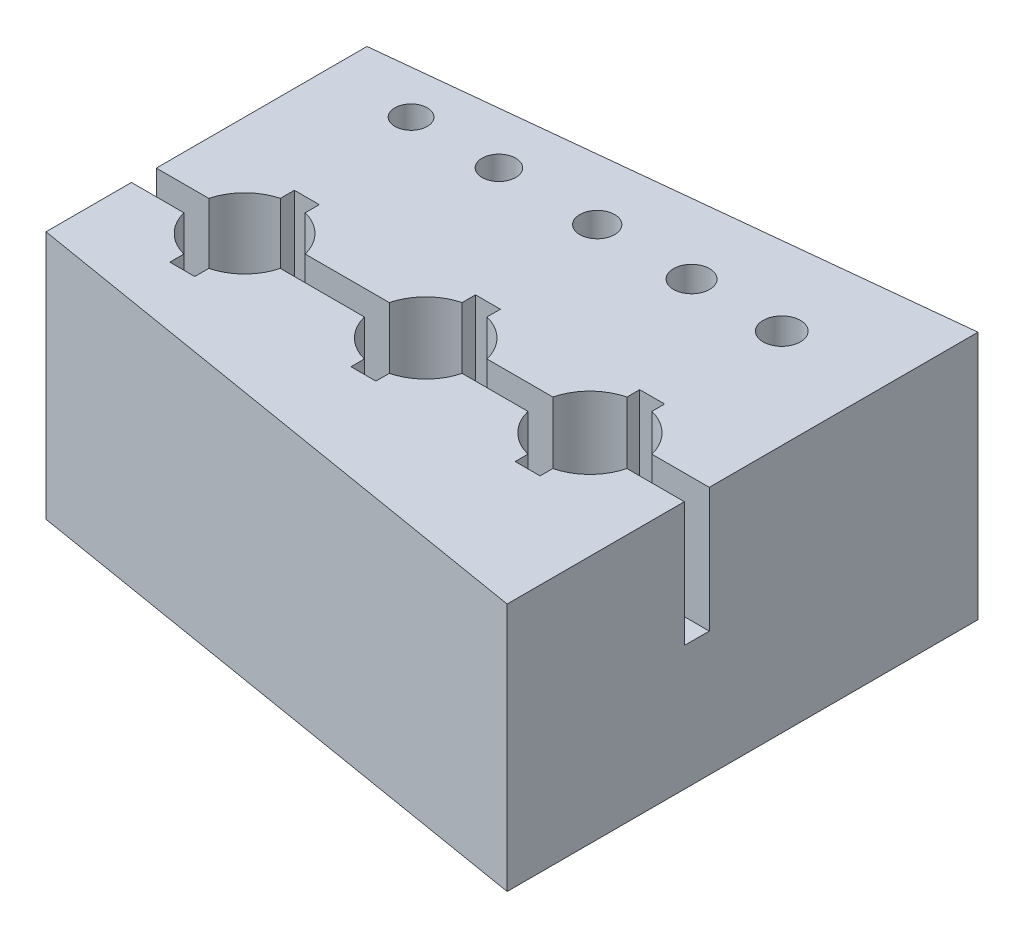
from build123d import *

# Parameters (mm, degrees)
SKETCH1_R           = 0.65
SKETCH1_R_2         = 0.675
SKETCH1_R_3         = 0.7
SKETCH1_R_4         = 0.725
SKETCH1_R_5         = 0.75
SKETCH1_W           = 1
SKETCH1_H           = 1
BOSS_EXTRUDE1_DEPTH = 10
CUT_EXTRUDE1_START  = 10
SKETCH1_4_W         = 1
SKETCH1_4_H         = 1
CUT_EXTRUDE1_DEPTH  = 5


with BuildPart() as part:
    # Sketch1 → Boss-Extrude1 (new body)
    with BuildSketch(Plane(origin=(0, 0, 0), x_dir=(1, 0, 0), z_dir=(0, 1, 0))):
        with BuildLine():
            Line((22.206609956, -4.676577902), (22.206609956, -1.693083106))
            Line((22.206609956, -1.693083106), (22.206609956, 6.115263516))
            Line((22.206609956, 6.115263516), (0, 3.783645885))
            Line((0, 3.783645885), (0, 1.993800458))
            Line((0, 1.993800458), (0, -4.676577902))
            Line((0, -4.676577902), (2.106823129, -4.676577902))
            ThreePointArc((2.106823129, -4.676577902), (2.62910124, -3.762364339), (3.543314802, -3.240086229))
            Line((3.543314802, -3.240086229), (3.543314802, -2.676577902))
            Line((3.543314802, -2.676577902), (4.543314802, -2.676577902))
            Line((4.543314802, -2.676577902), (4.543314802, -3.240086229))
            ThreePointArc((4.543314802, -3.240086229), (5.457528364, -3.762364339), (5.979806475, -4.676577902))
            Line((5.979806475, -4.676577902), (9.355611155, -4.676577902))
            ThreePointArc((9.355611155, -4.676577902), (9.886020869, -3.74468667), (10.8179121, -3.214276957))
            Line((10.8179121, -3.214276957), (10.8179121, -2.676577902))
            Line((10.8179121, -2.676577902), (11.8179121, -2.676577902))
            Line((11.8179121, -2.676577902), (11.8179121, -3.214276957))
            ThreePointArc((11.8179121, -3.214276957), (12.749803332, -3.74468667), (13.280213046, -4.676577902))
            Line((13.280213046, -4.676577902), (15.924027608, -4.676577902))
            ThreePointArc((15.924027608, -4.676577902), (16.462548242, -3.727009), (17.412117144, -3.188488367))
            Line((17.412117144, -3.188488367), (17.412117144, -2.676577902))
            Line((17.412117144, -2.676577902), (18.412117144, -2.676577902))
            Line((18.412117144, -2.676577902), (18.412117144, -3.188488367))
            ThreePointArc((18.412117144, -3.188488367), (19.361686045, -3.727009), (19.900206679, -4.676577902))
            Line((19.900206679, -4.676577902), (22.206609956, -4.676577902))
        make_face()
        with Locations((3.342327151, 2.211090205)):
            Circle(SKETCH1_R, mode=Mode.SUBTRACT)
        with Locations((6.870185956, 2.211090205)):
            Circle(SKETCH1_R_2, mode=Mode.SUBTRACT)
        with Locations((10.8179121, 2.211090205)):
            Circle(SKETCH1_R_3, mode=Mode.SUBTRACT)
        with Locations((14.607435977, 2.211090205)):
            Circle(SKETCH1_R_4, mode=Mode.SUBTRACT)
        with Locations((18.23001071, 2.211090205)):
            Circle(SKETCH1_R_5, mode=Mode.SUBTRACT)
        with BuildLine():
            Line((22.206609956, -12.794492927), (22.206609956, -5.676577902))
            Line((22.206609956, -5.676577902), (19.900206679, -5.676577902))
            ThreePointArc((19.900206679, -5.676577902), (19.361686045, -6.626146803), (18.412117144, -7.164667437))
            Line((18.412117144, -7.164667437), (18.412117144, -7.676577902))
            Line((18.412117144, -7.676577902), (17.412117144, -7.676577902))
            Line((17.412117144, -7.676577902), (17.412117144, -7.164667437))
            ThreePointArc((17.412117144, -7.164667437), (16.462548242, -6.626146803), (15.924027608, -5.676577902))
            Line((15.924027608, -5.676577902), (13.280213046, -5.676577902))
            ThreePointArc((13.280213046, -5.676577902), (12.749803332, -6.608469134), (11.8179121, -7.138878847))
            Line((11.8179121, -7.138878847), (11.8179121, -7.676577902))
            Line((11.8179121, -7.676577902), (10.8179121, -7.676577902))
            Line((10.8179121, -7.676577902), (10.8179121, -7.138878847))
            ThreePointArc((10.8179121, -7.138878847), (9.886020869, -6.608469134), (9.355611155, -5.676577902))
            Line((9.355611155, -5.676577902), (5.979806475, -5.676577902))
            ThreePointArc((5.979806475, -5.676577902), (5.457528364, -6.590791464), (4.543314802, -7.113069575))
            Line((4.543314802, -7.113069575), (4.543314802, -7.676577902))
            Line((4.543314802, -7.676577902), (3.543314802, -7.676577902))
            Line((3.543314802, -7.676577902), (3.543314802, -7.113069575))
            ThreePointArc((3.543314802, -7.113069575), (2.62910124, -6.590791464), (2.106823129, -5.676577902))
            Line((2.106823129, -5.676577902), (0, -5.676577902))
            Line((0, -5.676577902), (0, -9.107609363))
            Line((0, -9.107609363), (22.206609956, -12.794492927))
        make_face()
        with BuildLine():
            Line((22.206609956, -5.676577902), (22.206609956, -4.676577902))
            Line((22.206609956, -4.676577902), (19.900206679, -4.676577902))
            ThreePointArc((19.900206679, -4.676577902), (19.946580654, -4.924668739), (19.962117144, -5.176577902))
            ThreePointArc((19.962117144, -5.176577902), (19.946580654, -5.428487065), (19.900206679, -5.676577902))
            Line((19.900206679, -5.676577902), (22.206609956, -5.676577902))
        make_face()
        with BuildLine():
            ThreePointArc((19.962117144, -5.176577902), (19.946580654, -4.924668739), (19.900206679, -4.676577902))
            Line((19.900206679, -4.676577902), (18.412117144, -4.676577902))
            Line((18.412117144, -4.676577902), (18.412117144, -5.676577902))
            Line((18.412117144, -5.676577902), (19.900206679, -5.676577902))
            ThreePointArc((19.900206679, -5.676577902), (19.946580654, -5.428487065), (19.962117144, -5.176577902))
        make_face()
        with BuildLine():
            Line((18.412117144, -4.676577902), (19.900206679, -4.676577902))
            ThreePointArc((19.900206679, -4.676577902), (19.361686045, -3.727009), (18.412117144, -3.188488367))
            Line((18.412117144, -3.188488367), (18.412117144, -4.676577902))
        make_face()
        with BuildLine():
            ThreePointArc((17.412117144, -3.188488367), (17.912117144, -3.126577902), (18.412117144, -3.188488367))
            Line((18.412117144, -3.188488367), (18.412117144, -2.676577902))
            Line((18.412117144, -2.676577902), (17.412117144, -2.676577902))
            Line((17.412117144, -2.676577902), (17.412117144, -3.188488367))
        make_face()
        with BuildLine():
            Line((17.412117144, -4.676577902), (18.412117144, -4.676577902))
            Line((18.412117144, -4.676577902), (18.412117144, -3.188488367))
            ThreePointArc((18.412117144, -3.188488367), (17.912117144, -3.126577902), (17.412117144, -3.188488367))
            Line((17.412117144, -3.188488367), (17.412117144, -4.676577902))
        make_face()
        with BuildLine():
            ThreePointArc((18.412117144, -7.164667437), (19.361686045, -6.626146803), (19.900206679, -5.676577902))
            Line((19.900206679, -5.676577902), (18.412117144, -5.676577902))
            Line((18.412117144, -5.676577902), (18.412117144, -7.164667437))
        make_face()
        with BuildLine():
            Line((18.412117144, -7.164667437), (18.412117144, -5.676577902))
            Line((18.412117144, -5.676577902), (17.412117144, -5.676577902))
            Line((17.412117144, -5.676577902), (17.412117144, -7.164667437))
            ThreePointArc((17.412117144, -7.164667437), (17.912117144, -7.226577902), (18.412117144, -7.164667437))
        make_face()
        with BuildLine():
            Line((18.412117144, -7.676577902), (18.412117144, -7.164667437))
            ThreePointArc((18.412117144, -7.164667437), (17.912117144, -7.226577902), (17.412117144, -7.164667437))
            Line((17.412117144, -7.164667437), (17.412117144, -7.676577902))
            Line((17.412117144, -7.676577902), (18.412117144, -7.676577902))
        make_face()
        with Locations((17.912117144, -5.176577902)):
            Rectangle(SKETCH1_W, SKETCH1_H)
        with BuildLine():
            Line((17.412117144, -5.676577902), (17.412117144, -4.676577902))
            Line((17.412117144, -4.676577902), (15.924027608, -4.676577902))
            ThreePointArc((15.924027608, -4.676577902), (15.862117144, -5.176577902), (15.924027608, -5.676577902))
            Line((15.924027608, -5.676577902), (17.412117144, -5.676577902))
        make_face()
        with BuildLine():
            Line((15.924027608, -4.676577902), (17.412117144, -4.676577902))
            Line((17.412117144, -4.676577902), (17.412117144, -3.188488367))
            ThreePointArc((17.412117144, -3.188488367), (16.462548242, -3.727009), (15.924027608, -4.676577902))
        make_face()
        with BuildLine():
            Line((17.412117144, -7.164667437), (17.412117144, -5.676577902))
            Line((17.412117144, -5.676577902), (15.924027608, -5.676577902))
            ThreePointArc((15.924027608, -5.676577902), (16.462548242, -6.626146803), (17.412117144, -7.164667437))
        make_face()
        with BuildLine():
            ThreePointArc((15.924027608, -5.676577902), (15.862117144, -5.176577902), (15.924027608, -4.676577902))
            Line((15.924027608, -4.676577902), (13.280213046, -4.676577902))
            ThreePointArc((13.280213046, -4.676577902), (13.327176196, -4.924619983), (13.3429121, -5.176577902))
            ThreePointArc((13.3429121, -5.176577902), (13.327176196, -5.428535821), (13.280213046, -5.676577902))
            Line((13.280213046, -5.676577902), (15.924027608, -5.676577902))
        make_face()
        with BuildLine():
            Line((11.8179121, -4.676577902), (13.280213046, -4.676577902))
            ThreePointArc((13.280213046, -4.676577902), (12.749803332, -3.74468667), (11.8179121, -3.214276957))
            Line((11.8179121, -3.214276957), (11.8179121, -4.676577902))
        make_face()
        with BuildLine():
            ThreePointArc((10.8179121, -3.214276957), (11.3179121, -3.151577902), (11.8179121, -3.214276957))
            Line((11.8179121, -3.214276957), (11.8179121, -2.676577902))
            Line((11.8179121, -2.676577902), (10.8179121, -2.676577902))
            Line((10.8179121, -2.676577902), (10.8179121, -3.214276957))
        make_face()
        with BuildLine():
            Line((10.8179121, -4.676577902), (11.8179121, -4.676577902))
            Line((11.8179121, -4.676577902), (11.8179121, -3.214276957))
            ThreePointArc((11.8179121, -3.214276957), (11.3179121, -3.151577902), (10.8179121, -3.214276957))
            Line((10.8179121, -3.214276957), (10.8179121, -4.676577902))
        make_face()
        with BuildLine():
            ThreePointArc((13.3429121, -5.176577902), (13.327176196, -4.924619983), (13.280213046, -4.676577902))
            Line((13.280213046, -4.676577902), (11.8179121, -4.676577902))
            Line((11.8179121, -4.676577902), (11.8179121, -5.676577902))
            Line((11.8179121, -5.676577902), (13.280213046, -5.676577902))
            ThreePointArc((13.280213046, -5.676577902), (13.327176196, -5.428535821), (13.3429121, -5.176577902))
        make_face()
        with BuildLine():
            ThreePointArc((11.8179121, -7.138878847), (12.749803332, -6.608469134), (13.280213046, -5.676577902))
            Line((13.280213046, -5.676577902), (11.8179121, -5.676577902))
            Line((11.8179121, -5.676577902), (11.8179121, -7.138878847))
        make_face()
        with BuildLine():
            Line((11.8179121, -7.138878847), (11.8179121, -5.676577902))
            Line((11.8179121, -5.676577902), (10.8179121, -5.676577902))
            Line((10.8179121, -5.676577902), (10.8179121, -7.138878847))
            ThreePointArc((10.8179121, -7.138878847), (11.3179121, -7.201577902), (11.8179121, -7.138878847))
        make_face()
        with BuildLine():
            Line((11.8179121, -7.676577902), (11.8179121, -7.138878847))
            ThreePointArc((11.8179121, -7.138878847), (11.3179121, -7.201577902), (10.8179121, -7.138878847))
            Line((10.8179121, -7.138878847), (10.8179121, -7.676577902))
            Line((10.8179121, -7.676577902), (11.8179121, -7.676577902))
        make_face()
        with Locations((11.3179121, -5.176577902)):
            Rectangle(SKETCH1_W, SKETCH1_H)
        with BuildLine():
            Line((10.8179121, -5.676577902), (10.8179121, -4.676577902))
            Line((10.8179121, -4.676577902), (9.355611155, -4.676577902))
            ThreePointArc((9.355611155, -4.676577902), (9.2929121, -5.176577902), (9.355611155, -5.676577902))
            Line((9.355611155, -5.676577902), (10.8179121, -5.676577902))
        make_face()
        with BuildLine():
            Line((9.355611155, -4.676577902), (10.8179121, -4.676577902))
            Line((10.8179121, -4.676577902), (10.8179121, -3.214276957))
            ThreePointArc((10.8179121, -3.214276957), (9.886020869, -3.74468667), (9.355611155, -4.676577902))
        make_face()
        with BuildLine():
            Line((10.8179121, -7.138878847), (10.8179121, -5.676577902))
            Line((10.8179121, -5.676577902), (9.355611155, -5.676577902))
            ThreePointArc((9.355611155, -5.676577902), (9.886020869, -6.608469134), (10.8179121, -7.138878847))
        make_face()
        with BuildLine():
            Line((9.355611155, -4.676577902), (5.979806475, -4.676577902))
            ThreePointArc((5.979806475, -4.676577902), (6.027374194, -4.924569317), (6.043314802, -5.176577902))
            ThreePointArc((6.043314802, -5.176577902), (6.027374194, -5.428586487), (5.979806475, -5.676577902))
            Line((5.979806475, -5.676577902), (9.355611155, -5.676577902))
            ThreePointArc((9.355611155, -5.676577902), (9.2929121, -5.176577902), (9.355611155, -4.676577902))
        make_face()
        with BuildLine():
            Line((4.543314802, -3.240086229), (4.543314802, -4.676577902))
            Line((4.543314802, -4.676577902), (5.979806475, -4.676577902))
            ThreePointArc((5.979806475, -4.676577902), (5.457528364, -3.762364339), (4.543314802, -3.240086229))
        make_face()
        with BuildLine():
            Line((5.979806475, -4.676577902), (4.543314802, -4.676577902))
            Line((4.543314802, -4.676577902), (4.543314802, -5.676577902))
            Line((4.543314802, -5.676577902), (5.979806475, -5.676577902))
            ThreePointArc((5.979806475, -5.676577902), (6.027374194, -5.428586487), (6.043314802, -5.176577902))
            ThreePointArc((6.043314802, -5.176577902), (6.027374194, -4.924569317), (5.979806475, -4.676577902))
        make_face()
        with BuildLine():
            Line((5.979806475, -5.676577902), (4.543314802, -5.676577902))
            Line((4.543314802, -5.676577902), (4.543314802, -7.113069575))
            ThreePointArc((4.543314802, -7.113069575), (5.457528364, -6.590791464), (5.979806475, -5.676577902))
        make_face()
        with BuildLine():
            Line((4.543314802, -5.676577902), (3.543314802, -5.676577902))
            Line((3.543314802, -5.676577902), (3.543314802, -7.113069575))
            ThreePointArc((3.543314802, -7.113069575), (4.043314802, -7.176577902), (4.543314802, -7.113069575))
            Line((4.543314802, -7.113069575), (4.543314802, -5.676577902))
        make_face()
        with BuildLine():
            ThreePointArc((4.543314802, -7.113069575), (4.043314802, -7.176577902), (3.543314802, -7.113069575))
            Line((3.543314802, -7.113069575), (3.543314802, -7.676577902))
            Line((3.543314802, -7.676577902), (4.543314802, -7.676577902))
            Line((4.543314802, -7.676577902), (4.543314802, -7.113069575))
        make_face()
        with BuildLine():
            Line((3.543314802, -5.676577902), (2.106823129, -5.676577902))
            ThreePointArc((2.106823129, -5.676577902), (2.62910124, -6.590791464), (3.543314802, -7.113069575))
            Line((3.543314802, -7.113069575), (3.543314802, -5.676577902))
        make_face()
        with BuildLine():
            Line((3.543314802, -4.676577902), (2.106823129, -4.676577902))
            ThreePointArc((2.106823129, -4.676577902), (2.043314802, -5.176577902), (2.106823129, -5.676577902))
            Line((2.106823129, -5.676577902), (3.543314802, -5.676577902))
            Line((3.543314802, -5.676577902), (3.543314802, -4.676577902))
        make_face()
        with Locations((4.043314802, -5.176577902)):
            Rectangle(SKETCH1_W, SKETCH1_H)
        with BuildLine():
            Line((3.543314802, -3.240086229), (3.543314802, -4.676577902))
            Line((3.543314802, -4.676577902), (4.543314802, -4.676577902))
            Line((4.543314802, -4.676577902), (4.543314802, -3.240086229))
            ThreePointArc((4.543314802, -3.240086229), (4.043314802, -3.176577902), (3.543314802, -3.240086229))
        make_face()
        with BuildLine():
            Line((3.543314802, -2.676577902), (3.543314802, -3.240086229))
            ThreePointArc((3.543314802, -3.240086229), (4.043314802, -3.176577902), (4.543314802, -3.240086229))
            Line((4.543314802, -3.240086229), (4.543314802, -2.676577902))
            Line((4.543314802, -2.676577902), (3.543314802, -2.676577902))
        make_face()
        with BuildLine():
            ThreePointArc((3.543314802, -3.240086229), (2.62910124, -3.762364339), (2.106823129, -4.676577902))
            Line((2.106823129, -4.676577902), (3.543314802, -4.676577902))
            Line((3.543314802, -4.676577902), (3.543314802, -3.240086229))
        make_face()
        with BuildLine():
            Line((2.106823129, -4.676577902), (0, -4.676577902))
            Line((0, -4.676577902), (0, -5.676577902))
            Line((0, -5.676577902), (2.106823129, -5.676577902))
            ThreePointArc((2.106823129, -5.676577902), (2.043314802, -5.176577902), (2.106823129, -4.676577902))
        make_face()
    extrude(amount=BOSS_EXTRUDE1_DEPTH)

    # Sketch1_4 → Cut-Extrude1 (cut)
    with BuildSketch(Plane(origin=(0, 0, 0), x_dir=(1, 0, 0), z_dir=(0, 1, 0)).offset(CUT_EXTRUDE1_START)):
        with BuildLine():
            Line((22.206609956, -5.676577902), (22.206609956, -4.676577902))
            Line((22.206609956, -4.676577902), (19.900206679, -4.676577902))
            ThreePointArc((19.900206679, -4.676577902), (19.946580654, -4.924668739), (19.962117144, -5.176577902))
            ThreePointArc((19.962117144, -5.176577902), (19.946580654, -5.428487065), (19.900206679, -5.676577902))
            Line((19.900206679, -5.676577902), (22.206609956, -5.676577902))
        make_face()
        with BuildLine():
            ThreePointArc((19.962117144, -5.176577902), (19.946580654, -4.924668739), (19.900206679, -4.676577902))
            Line((19.900206679, -4.676577902), (18.412117144, -4.676577902))
            Line((18.412117144, -4.676577902), (18.412117144, -5.676577902))
            Line((18.412117144, -5.676577902), (19.900206679, -5.676577902))
            ThreePointArc((19.900206679, -5.676577902), (19.946580654, -5.428487065), (19.962117144, -5.176577902))
        make_face()
        with BuildLine():
            Line((18.412117144, -4.676577902), (19.900206679, -4.676577902))
            ThreePointArc((19.900206679, -4.676577902), (19.361686045, -3.727009), (18.412117144, -3.188488367))
            Line((18.412117144, -3.188488367), (18.412117144, -4.676577902))
        make_face()
        with BuildLine():
            ThreePointArc((18.412117144, -7.164667437), (19.361686045, -6.626146803), (19.900206679, -5.676577902))
            Line((19.900206679, -5.676577902), (18.412117144, -5.676577902))
            Line((18.412117144, -5.676577902), (18.412117144, -7.164667437))
        make_face()
        with BuildLine():
            Line((18.412117144, -7.676577902), (18.412117144, -7.164667437))
            ThreePointArc((18.412117144, -7.164667437), (17.912117144, -7.226577902), (17.412117144, -7.164667437))
            Line((17.412117144, -7.164667437), (17.412117144, -7.676577902))
            Line((17.412117144, -7.676577902), (18.412117144, -7.676577902))
        make_face()
        with BuildLine():
            Line((18.412117144, -7.164667437), (18.412117144, -5.676577902))
            Line((18.412117144, -5.676577902), (17.412117144, -5.676577902))
            Line((17.412117144, -5.676577902), (17.412117144, -7.164667437))
            ThreePointArc((17.412117144, -7.164667437), (17.912117144, -7.226577902), (18.412117144, -7.164667437))
        make_face()
        with Locations((17.912117144, -5.176577902)):
            Rectangle(SKETCH1_4_W, SKETCH1_4_H)
        with BuildLine():
            Line((17.412117144, -4.676577902), (18.412117144, -4.676577902))
            Line((18.412117144, -4.676577902), (18.412117144, -3.188488367))
            ThreePointArc((18.412117144, -3.188488367), (17.912117144, -3.126577902), (17.412117144, -3.188488367))
            Line((17.412117144, -3.188488367), (17.412117144, -4.676577902))
        make_face()
        with BuildLine():
            ThreePointArc((17.412117144, -3.188488367), (17.912117144, -3.126577902), (18.412117144, -3.188488367))
            Line((18.412117144, -3.188488367), (18.412117144, -2.676577902))
            Line((18.412117144, -2.676577902), (17.412117144, -2.676577902))
            Line((17.412117144, -2.676577902), (17.412117144, -3.188488367))
        make_face()
        with BuildLine():
            Line((15.924027608, -4.676577902), (17.412117144, -4.676577902))
            Line((17.412117144, -4.676577902), (17.412117144, -3.188488367))
            ThreePointArc((17.412117144, -3.188488367), (16.462548242, -3.727009), (15.924027608, -4.676577902))
        make_face()
        with BuildLine():
            Line((17.412117144, -5.676577902), (17.412117144, -4.676577902))
            Line((17.412117144, -4.676577902), (15.924027608, -4.676577902))
            ThreePointArc((15.924027608, -4.676577902), (15.862117144, -5.176577902), (15.924027608, -5.676577902))
            Line((15.924027608, -5.676577902), (17.412117144, -5.676577902))
        make_face()
        with BuildLine():
            Line((17.412117144, -7.164667437), (17.412117144, -5.676577902))
            Line((17.412117144, -5.676577902), (15.924027608, -5.676577902))
            ThreePointArc((15.924027608, -5.676577902), (16.462548242, -6.626146803), (17.412117144, -7.164667437))
        make_face()
        with BuildLine():
            ThreePointArc((15.924027608, -5.676577902), (15.862117144, -5.176577902), (15.924027608, -4.676577902))
            Line((15.924027608, -4.676577902), (13.280213046, -4.676577902))
            ThreePointArc((13.280213046, -4.676577902), (13.327176196, -4.924619983), (13.3429121, -5.176577902))
            ThreePointArc((13.3429121, -5.176577902), (13.327176196, -5.428535821), (13.280213046, -5.676577902))
            Line((13.280213046, -5.676577902), (15.924027608, -5.676577902))
        make_face()
        with BuildLine():
            ThreePointArc((13.3429121, -5.176577902), (13.327176196, -4.924619983), (13.280213046, -4.676577902))
            Line((13.280213046, -4.676577902), (11.8179121, -4.676577902))
            Line((11.8179121, -4.676577902), (11.8179121, -5.676577902))
            Line((11.8179121, -5.676577902), (13.280213046, -5.676577902))
            ThreePointArc((13.280213046, -5.676577902), (13.327176196, -5.428535821), (13.3429121, -5.176577902))
        make_face()
        with BuildLine():
            ThreePointArc((11.8179121, -7.138878847), (12.749803332, -6.608469134), (13.280213046, -5.676577902))
            Line((13.280213046, -5.676577902), (11.8179121, -5.676577902))
            Line((11.8179121, -5.676577902), (11.8179121, -7.138878847))
        make_face()
        with BuildLine():
            Line((11.8179121, -7.676577902), (11.8179121, -7.138878847))
            ThreePointArc((11.8179121, -7.138878847), (11.3179121, -7.201577902), (10.8179121, -7.138878847))
            Line((10.8179121, -7.138878847), (10.8179121, -7.676577902))
            Line((10.8179121, -7.676577902), (11.8179121, -7.676577902))
        make_face()
        with BuildLine():
            Line((11.8179121, -7.138878847), (11.8179121, -5.676577902))
            Line((11.8179121, -5.676577902), (10.8179121, -5.676577902))
            Line((10.8179121, -5.676577902), (10.8179121, -7.138878847))
            ThreePointArc((10.8179121, -7.138878847), (11.3179121, -7.201577902), (11.8179121, -7.138878847))
        make_face()
        with Locations((11.3179121, -5.176577902)):
            Rectangle(SKETCH1_4_W, SKETCH1_4_H)
        with BuildLine():
            Line((10.8179121, -4.676577902), (11.8179121, -4.676577902))
            Line((11.8179121, -4.676577902), (11.8179121, -3.214276957))
            ThreePointArc((11.8179121, -3.214276957), (11.3179121, -3.151577902), (10.8179121, -3.214276957))
            Line((10.8179121, -3.214276957), (10.8179121, -4.676577902))
        make_face()
        with BuildLine():
            Line((11.8179121, -4.676577902), (13.280213046, -4.676577902))
            ThreePointArc((13.280213046, -4.676577902), (12.749803332, -3.74468667), (11.8179121, -3.214276957))
            Line((11.8179121, -3.214276957), (11.8179121, -4.676577902))
        make_face()
        with BuildLine():
            ThreePointArc((10.8179121, -3.214276957), (11.3179121, -3.151577902), (11.8179121, -3.214276957))
            Line((11.8179121, -3.214276957), (11.8179121, -2.676577902))
            Line((11.8179121, -2.676577902), (10.8179121, -2.676577902))
            Line((10.8179121, -2.676577902), (10.8179121, -3.214276957))
        make_face()
        with BuildLine():
            Line((9.355611155, -4.676577902), (10.8179121, -4.676577902))
            Line((10.8179121, -4.676577902), (10.8179121, -3.214276957))
            ThreePointArc((10.8179121, -3.214276957), (9.886020869, -3.74468667), (9.355611155, -4.676577902))
        make_face()
        with BuildLine():
            Line((10.8179121, -5.676577902), (10.8179121, -4.676577902))
            Line((10.8179121, -4.676577902), (9.355611155, -4.676577902))
            ThreePointArc((9.355611155, -4.676577902), (9.2929121, -5.176577902), (9.355611155, -5.676577902))
            Line((9.355611155, -5.676577902), (10.8179121, -5.676577902))
        make_face()
        with BuildLine():
            Line((10.8179121, -7.138878847), (10.8179121, -5.676577902))
            Line((10.8179121, -5.676577902), (9.355611155, -5.676577902))
            ThreePointArc((9.355611155, -5.676577902), (9.886020869, -6.608469134), (10.8179121, -7.138878847))
        make_face()
        with BuildLine():
            Line((9.355611155, -4.676577902), (5.979806475, -4.676577902))
            ThreePointArc((5.979806475, -4.676577902), (6.027374194, -4.924569317), (6.043314802, -5.176577902))
            ThreePointArc((6.043314802, -5.176577902), (6.027374194, -5.428586487), (5.979806475, -5.676577902))
            Line((5.979806475, -5.676577902), (9.355611155, -5.676577902))
            ThreePointArc((9.355611155, -5.676577902), (9.2929121, -5.176577902), (9.355611155, -4.676577902))
        make_face()
        with BuildLine():
            Line((5.979806475, -4.676577902), (4.543314802, -4.676577902))
            Line((4.543314802, -4.676577902), (4.543314802, -5.676577902))
            Line((4.543314802, -5.676577902), (5.979806475, -5.676577902))
            ThreePointArc((5.979806475, -5.676577902), (6.027374194, -5.428586487), (6.043314802, -5.176577902))
            ThreePointArc((6.043314802, -5.176577902), (6.027374194, -4.924569317), (5.979806475, -4.676577902))
        make_face()
        with BuildLine():
            Line((4.543314802, -3.240086229), (4.543314802, -4.676577902))
            Line((4.543314802, -4.676577902), (5.979806475, -4.676577902))
            ThreePointArc((5.979806475, -4.676577902), (5.457528364, -3.762364339), (4.543314802, -3.240086229))
        make_face()
        with BuildLine():
            Line((3.543314802, -2.676577902), (3.543314802, -3.240086229))
            ThreePointArc((3.543314802, -3.240086229), (4.043314802, -3.176577902), (4.543314802, -3.240086229))
            Line((4.543314802, -3.240086229), (4.543314802, -2.676577902))
            Line((4.543314802, -2.676577902), (3.543314802, -2.676577902))
        make_face()
        with BuildLine():
            Line((3.543314802, -3.240086229), (3.543314802, -4.676577902))
            Line((3.543314802, -4.676577902), (4.543314802, -4.676577902))
            Line((4.543314802, -4.676577902), (4.543314802, -3.240086229))
            ThreePointArc((4.543314802, -3.240086229), (4.043314802, -3.176577902), (3.543314802, -3.240086229))
        make_face()
        with BuildLine():
            Line((4.543314802, -5.676577902), (3.543314802, -5.676577902))
            Line((3.543314802, -5.676577902), (3.543314802, -7.113069575))
            ThreePointArc((3.543314802, -7.113069575), (4.043314802, -7.176577902), (4.543314802, -7.113069575))
            Line((4.543314802, -7.113069575), (4.543314802, -5.676577902))
        make_face()
        with Locations((4.043314802, -5.176577902)):
            Rectangle(SKETCH1_4_W, SKETCH1_4_H)
        with BuildLine():
            Line((5.979806475, -5.676577902), (4.543314802, -5.676577902))
            Line((4.543314802, -5.676577902), (4.543314802, -7.113069575))
            ThreePointArc((4.543314802, -7.113069575), (5.457528364, -6.590791464), (5.979806475, -5.676577902))
        make_face()
        with BuildLine():
            ThreePointArc((4.543314802, -7.113069575), (4.043314802, -7.176577902), (3.543314802, -7.113069575))
            Line((3.543314802, -7.113069575), (3.543314802, -7.676577902))
            Line((3.543314802, -7.676577902), (4.543314802, -7.676577902))
            Line((4.543314802, -7.676577902), (4.543314802, -7.113069575))
        make_face()
        with BuildLine():
            Line((3.543314802, -5.676577902), (2.106823129, -5.676577902))
            ThreePointArc((2.106823129, -5.676577902), (2.62910124, -6.590791464), (3.543314802, -7.113069575))
            Line((3.543314802, -7.113069575), (3.543314802, -5.676577902))
        make_face()
        with BuildLine():
            Line((3.543314802, -4.676577902), (2.106823129, -4.676577902))
            ThreePointArc((2.106823129, -4.676577902), (2.043314802, -5.176577902), (2.106823129, -5.676577902))
            Line((2.106823129, -5.676577902), (3.543314802, -5.676577902))
            Line((3.543314802, -5.676577902), (3.543314802, -4.676577902))
        make_face()
        with BuildLine():
            ThreePointArc((3.543314802, -3.240086229), (2.62910124, -3.762364339), (2.106823129, -4.676577902))
            Line((2.106823129, -4.676577902), (3.543314802, -4.676577902))
            Line((3.543314802, -4.676577902), (3.543314802, -3.240086229))
        make_face()
        with BuildLine():
            Line((2.106823129, -4.676577902), (0, -4.676577902))
            Line((0, -4.676577902), (0, -5.676577902))
            Line((0, -5.676577902), (2.106823129, -5.676577902))
            ThreePointArc((2.106823129, -5.676577902), (2.043314802, -5.176577902), (2.106823129, -4.676577902))
        make_face()
    extrude(amount=-CUT_EXTRUDE1_DEPTH, mode=Mode.SUBTRACT)


solid = part.part
